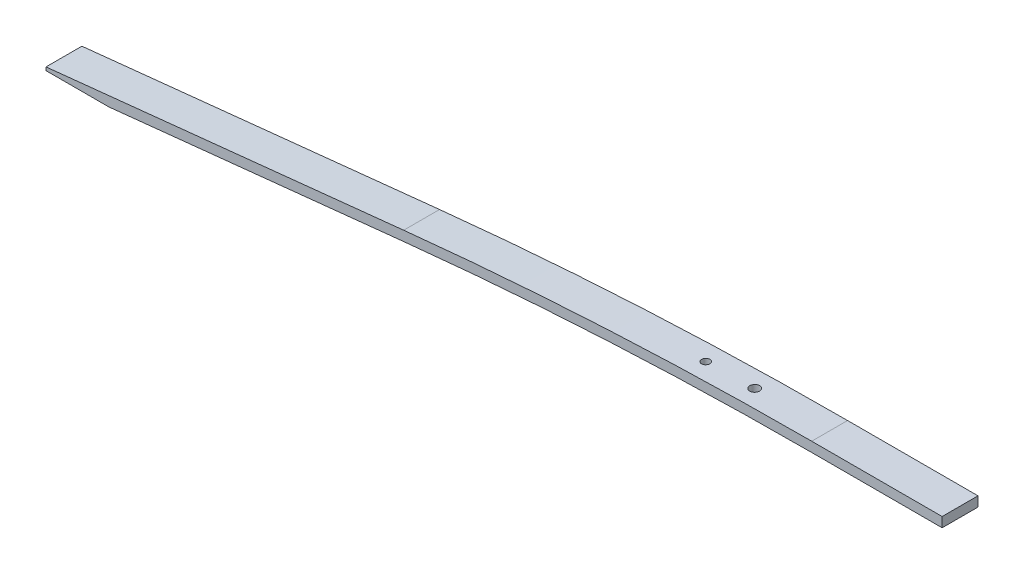
from build123d import *

# Parameters (mm, degrees)
EXTRUDE1_DEPTH     = 5.5
SKETCH2_R          = 1.5
SKETCH2_R_2        = 1.25
CUT_EXTRUDE1_DEPTH = 22.5


with BuildPart() as part:
    # Sketch1 → Extrude1 (new body, symmetric)
    with BuildSketch(Plane.XY):
        with BuildLine():
            Line((-164.827821897, 11.989846995), (-255.561088457, 2.5))
            Line((-255.561088457, 2.5), (-274.839724553, 2.5))
            Line((-274.839724553, 2.5), (-274.839724553, 3.5))
            Line((-274.839724553, 3.5), (-165.139891452, 14.973571613))
            ThreePointArc((-165.139891452, 14.973571613), (-102.654981247, 19.86728494), (-40, 21.5))
            Line((-40, 21.5), (0, 21.5))
            Line((0, 21.5), (0, 18.5))
            Line((0, 18.5), (-40, 18.5))
            ThreePointArc((-40, 18.5), (-102.498734411, 16.871356549), (-164.827821897, 11.989846995))
        make_face()
    extrude(amount=EXTRUDE1_DEPTH, both=True)

    # Sketch2 → Cut-Extrude1 (cut, through all)
    with BuildSketch(Plane(origin=(0, 0, 0), x_dir=(1, 0, 0), z_dir=(0, 1, 0))):
        with Locations(Location((-63, 0, 0), (0, 0, 90))):  # turned: the seam where the file's is
            Circle(SKETCH2_R)
        with Locations(Location((-78, 0, 0), (0, 0, 90))):  # turned: the seam where the file's is
            Circle(SKETCH2_R_2)
    extrude(amount=CUT_EXTRUDE1_DEPTH, mode=Mode.SUBTRACT)


solid = part.part
